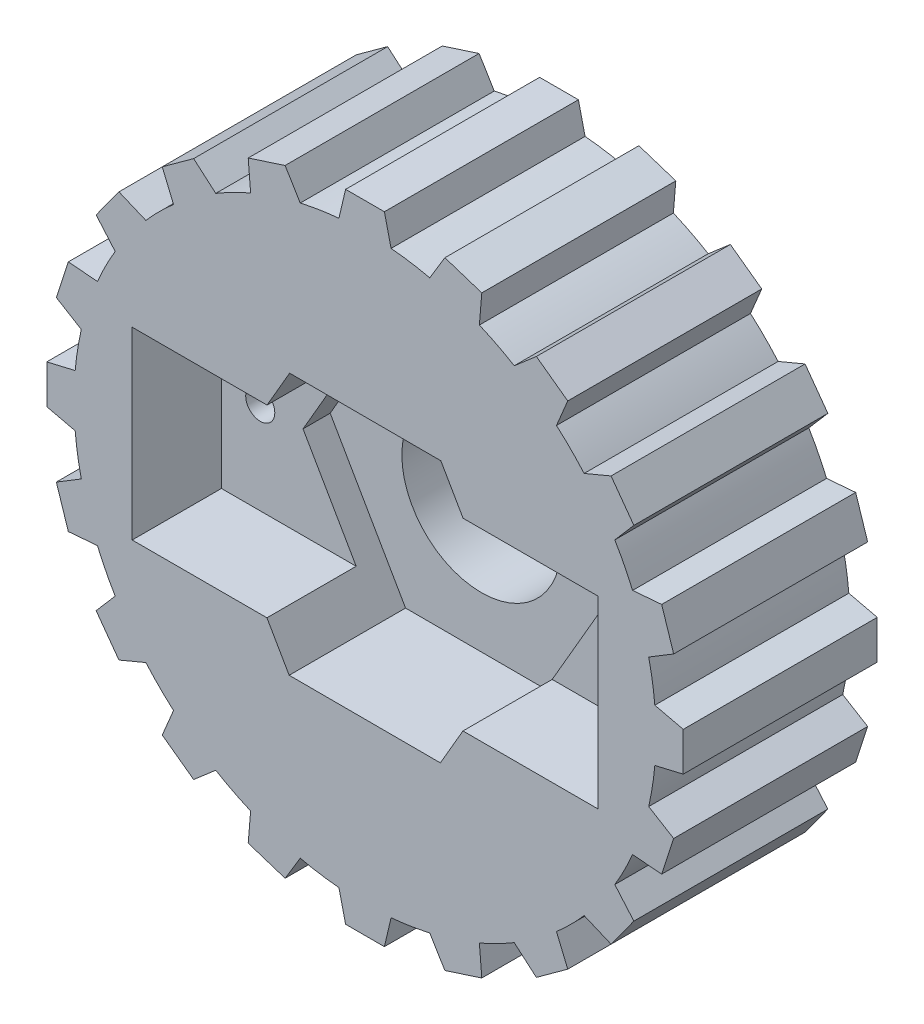
from build123d import *

# Parameters (mm, degrees)
SKETCH1_R                      = 15
EXTRUDE1_DEPTH                 = 10
EXTRUDE3_DEPTH                 = 10
CIRPATTERN1_COUNT              = 20
F_8_2_8_2_DIAMETER_HOLE1_D     = 8.2
F_8_2_8_2_DIAMETER_HOLE1_DEPTH = 10
F_8_2_8_2_DIAMETER_HOLE1_TIP   = 2.463528538
SKETCH4_W                      = 24
SKETCH4_H                      = 9.5
EXTRUDE4_DEPTH                 = 4.6
F_1_5_1_5_DIAMETER_HOLE1_D     = 1.5
F_1_5_1_5_DIAMETER_HOLE1_DEPTH = 150
F_1_5_1_5_DIAMETER_HOLE1_TIP   = 0.450645464
EXTRUDE5_DEPTH                 = 6


with BuildPart() as part:
    # Sketch1 → Extrude1 (new body)
    with BuildSketch(Plane.XY):
        Circle(SKETCH1_R)
    extrude(amount=EXTRUDE1_DEPTH)

    # Sketch2 → Extrude3 (add)
    with BuildSketch(Plane.XY.offset(10)):
        Polygon((1.4, 14.704480908), (1, 16.404480908), (-1, 16.404480908), (-1.4, 14.704480908), align=None)
    extrude3 = extrude(amount=-EXTRUDE3_DEPTH)

    # CirPattern1: Extrude3 ×20 about axis
    cirpattern1_axis = Axis((0, 0, 0), (0, 0, 1))
    for i in range(1, CIRPATTERN1_COUNT):
        add(extrude3.rotate(cirpattern1_axis, i * 360 / CIRPATTERN1_COUNT))

    # Ø8.2 (8.2) Diameter Hole1
    with Locations(Plane(origin=(0, 0, 0), x_dir=(-1, 0, 0), z_dir=(0, 0, -1))):
        with Locations((0, 0)):
            Hole(F_8_2_8_2_DIAMETER_HOLE1_D / 2, depth=F_8_2_8_2_DIAMETER_HOLE1_DEPTH)
            with Locations((0, 0, -(F_8_2_8_2_DIAMETER_HOLE1_DEPTH + F_8_2_8_2_DIAMETER_HOLE1_TIP / 2))):  # 118° drill point
                Cone(0, F_8_2_8_2_DIAMETER_HOLE1_D / 2, F_8_2_8_2_DIAMETER_HOLE1_TIP, mode=Mode.SUBTRACT)

    # Sketch4 → Extrude4 (cut)
    with BuildSketch(Plane.XY.offset(10)):
        Rectangle(SKETCH4_W, SKETCH4_H)
    extrude(amount=-EXTRUDE4_DEPTH, mode=Mode.SUBTRACT)

    # Ø1.5 (1.5) Diameter Hole1
    with Locations(Plane(origin=(10, 0, 0), x_dir=(-1, 0, 0), z_dir=(0, 0, -1))):
        with Locations((0, 0), (20, 0)):
            Hole(F_1_5_1_5_DIAMETER_HOLE1_D / 2, depth=F_1_5_1_5_DIAMETER_HOLE1_DEPTH)
            with Locations((0, 0, -(F_1_5_1_5_DIAMETER_HOLE1_DEPTH + F_1_5_1_5_DIAMETER_HOLE1_TIP / 2))):  # 118° drill point
                Cone(0, F_1_5_1_5_DIAMETER_HOLE1_D / 2, F_1_5_1_5_DIAMETER_HOLE1_TIP, mode=Mode.SUBTRACT)

    # Sketch6 → Extrude5 (cut)
    with BuildSketch(Plane.XY.offset(10)):
        Polygon((3.908986866, 6.743131445), (-3.885229699, 6.756847651), (-7.794216565, 0.013716207), (-3.908986866, -6.743131445), (3.885229699, -6.756847651), (7.794216565, -0.013716207), align=None)
    extrude(amount=-EXTRUDE5_DEPTH, mode=Mode.SUBTRACT)


solid = part.part
